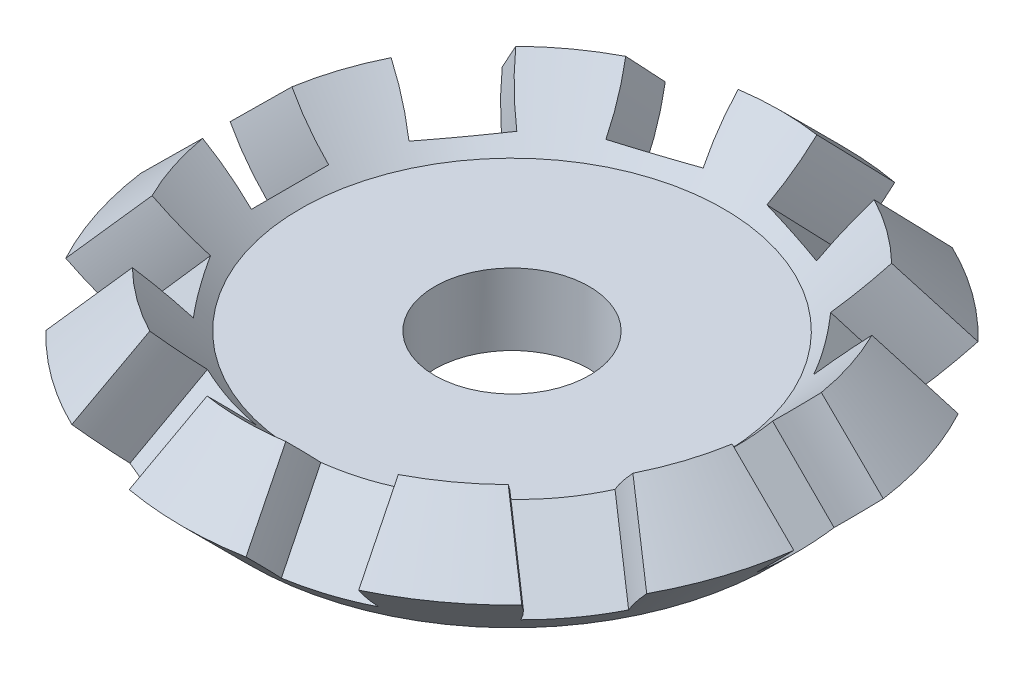
from build123d import *

# Parameters (mm, degrees)
CUT_EXTRUDE1_START = -2.681222
CUT_EXTRUDE1_DEPTH = 2.681222
CIRPATTERN3_COUNT  = 10
CUT_EXTRUDE2_REACH = 4.151
SKETCH5_R          = 2.323


with BuildPart() as part:
    # Sketch2 → Revolve2 (revolve)
    with BuildSketch(Plane(origin=(0, 0, 0), x_dir=(0, 0, -1), z_dir=(1, 0, 0))):
        Polygon((0, 0), (-7.8982, 0), (-9.91802604, 2.01982604), (-8.078303901, 3.859548179), (-6.369990486, 2.151234764), (0, 2.151234764), align=None)
    revolve(axis=Axis((0, 2.151234764, 0), (0, -1, 0)))

    # Sketch4 → Cut-Extrude1 (cut)
    with BuildSketch(Plane(origin=(-3.9491, -3.9491, 0), x_dir=(0, 0, 1), z_dir=(-0.707106781, -0.707106781, 0)).offset(CUT_EXTRUDE1_START)):
        with BuildLine():
            Line((-1.1615, 6.535539097), (1.1615, 6.535539097))
            ThreePointArc((1.1615, 6.535539097), (1.823938006, 9.981104914), (3.7168, 12.935393557))
            Line((3.7168, 12.935393557), (-3.7168, 12.935393557))
            ThreePointArc((-3.7168, 12.935393557), (-1.823938006, 9.981104914), (-1.1615, 6.535539097))
        make_face()
    cut_extrude1 = extrude(amount=CUT_EXTRUDE1_DEPTH, mode=Mode.SUBTRACT)

    # CirPattern3: Cut-Extrude1 ×10 about axis
    cirpattern3_axis = Axis((0, 0, 0), (0, 1, 0))
    for i in range(1, CIRPATTERN3_COUNT):
        add(cut_extrude1.rotate(cirpattern3_axis, i * 360 / CIRPATTERN3_COUNT), mode=Mode.SUBTRACT)

    # Sketch5 → Cut-Extrude2 (cut, up to next)
    with BuildSketch(Plane(origin=(0, 2.151234764, 0), x_dir=(1, 0, 0), z_dir=(0, 1, 0)), mode=Mode.PRIVATE) as cut_extrude2_sk1:
        Circle(SKETCH5_R)
    cut_extrude2_tool1 = extrude(cut_extrude2_sk1.sketch, amount=-CUT_EXTRUDE2_REACH, mode=Mode.PRIVATE) & part.part
    add(cut_extrude2_tool1.solids().sort_by_distance((0, 2.151235, 0))[0], mode=Mode.SUBTRACT)


solid = part.part
